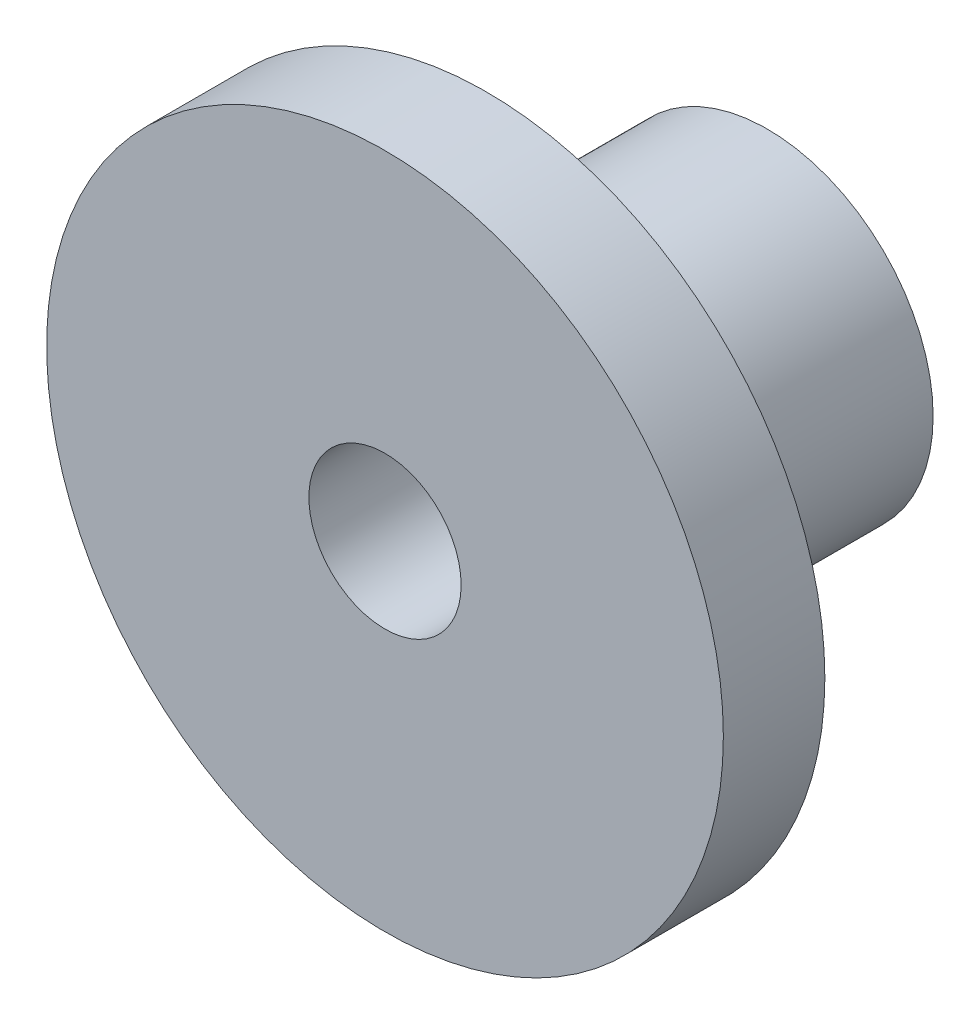
from build123d import *

# Parameters (mm, degrees)
SKETCH1_R           = 4.9
SKETCH1_R_2         = 2.25
BOSS_EXTRUDE1_DEPTH = 4.15
SKETCH2_R           = 10
SKETCH2_R_2         = 2.25
BOSS_EXTRUDE2_DEPTH = 3


with BuildPart() as part:
    # Sketch1 → Boss-Extrude1 (new body, symmetric)
    with BuildSketch(Plane.XY):
        Circle(SKETCH1_R)
        Circle(SKETCH1_R_2, mode=Mode.SUBTRACT)
    extrude(amount=BOSS_EXTRUDE1_DEPTH, both=True)

    # Sketch2 → Boss-Extrude2 (add)
    with BuildSketch(Plane.XY.offset(4.15)):
        Circle(SKETCH2_R)
        Circle(SKETCH2_R_2, mode=Mode.SUBTRACT)
    extrude(amount=BOSS_EXTRUDE2_DEPTH)


solid = part.part
